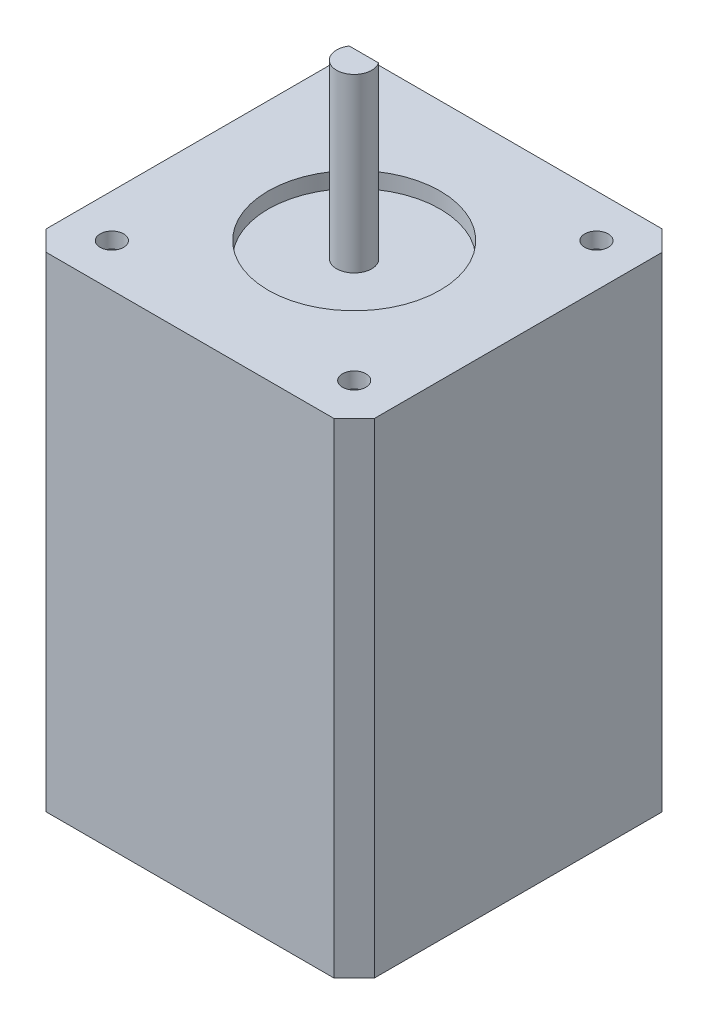
from build123d import *

# Parameters (mm, degrees)
EXTRUDE_1_DEPTH      = 2
EXTRUDE_1_DEPTH_BACK = 60
SKETCH_1_R           = 1.5
SKETCH_1_R_2         = 11
EXTRUDE_2_DEPTH      = 22
SKETCH_2_R           = 11
SKETCH_2_R_2         = 1.5
EXTRUDE_3_DEPTH      = 60


with BuildPart() as part:
    # 草图1 → 凸台-拉伸1 (new, two sides: drawn at the far end of the back side and taken through both)
    with BuildSketch(Plane(origin=(0, 0, 0), x_dir=(1, 0, 0), z_dir=(0, 1, 0)).offset(-EXTRUDE_1_DEPTH_BACK)):
        Polygon((-18.315463918, 21), (-21, 18.315463918), (-21, -18.402061856), (-18.402061856, -21), (18.402061856, -21), (21, -18.402061856), (21, 18.358762887), (18.358762887, 21), align=None)
        with Locations((-15.5, -15.5)):
            Circle(SKETCH_1_R, mode=Mode.SUBTRACT)
        with Locations((15.5, -15.5)):
            Circle(SKETCH_1_R, mode=Mode.SUBTRACT)
        Circle(SKETCH_1_R_2, mode=Mode.SUBTRACT)
        with Locations((-15.5, 15.5)):
            Circle(SKETCH_1_R, mode=Mode.SUBTRACT)
        with Locations((15.5, 15.5)):
            Circle(SKETCH_1_R, mode=Mode.SUBTRACT)
    extrude(amount=EXTRUDE_1_DEPTH + EXTRUDE_1_DEPTH_BACK)



with BuildPart() as body_2:
    # 草图1<3> → 凸台-拉伸2 (new body)
    with BuildSketch(Plane(origin=(0, 0, 0), x_dir=(1, 0, 0), z_dir=(0, 1, 0))):
        with BuildLine():
            Line((1.870828693, 1.25), (-1.870828693, 1.25))
            ThreePointArc((-1.870828693, 1.25), (-0.65312152, -2.15312152), (2.25, 0))
            ThreePointArc((2.25, 0), (2.15312152, 0.65312152), (1.870828693, 1.25))
        make_face()
    extrude(amount=EXTRUDE_2_DEPTH)


with BuildPart() as part_1:
    add(part.part)

    add(body_2.part)  # 凸台-拉伸3 merges body 2
    # 草图2 → 凸台-拉伸3 (add)
    with BuildSketch(Plane.XZ.offset(60)):
        Circle(SKETCH_2_R)
        with Locations((-15.5, 15.5)):
            Circle(SKETCH_2_R_2)
        with Locations((15.5, 15.5)):
            Circle(SKETCH_2_R_2)
        with Locations((-15.5, -15.5)):
            Circle(SKETCH_2_R_2)
        with Locations((15.5, -15.5)):
            Circle(SKETCH_2_R_2)
    extrude(amount=-EXTRUDE_3_DEPTH)


solid = part_1.part
